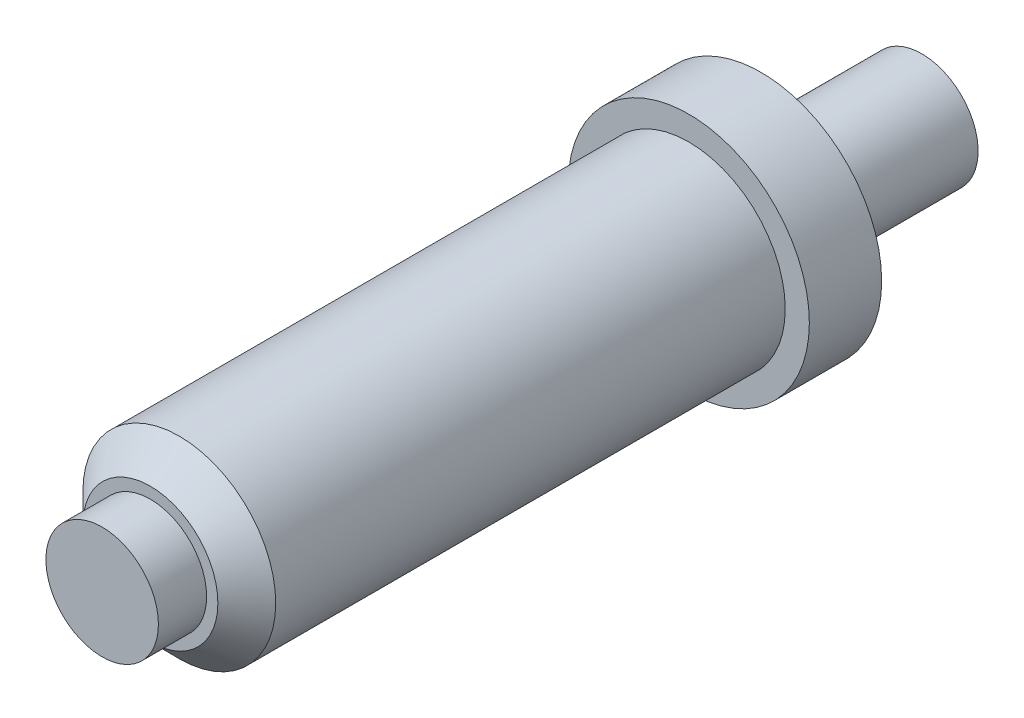
from build123d import *

# Parameters (mm, degrees)
SKETCH_1_R      = 6
EXTRUDE_1_DEPTH = 38
SKETCH_2_R      = 3.5
EXTRUDE_2_DEPTH = 3
SKETCH_4_R      = 3.5
EXTRUDE_3_DEPTH = 10
SKETCH_6_R      = 7.5
EXTRUDE_5_DEPTH = 4.5
CHAMFER_1_SIZE  = 1.8


with BuildPart() as part:
    # Эскиз1 → Бобышка-Вытянуть1 (new body)
    with BuildSketch(Plane.XY):
        Circle(SKETCH_1_R)
    extrude(amount=EXTRUDE_1_DEPTH)

    # Эскиз2 → Бобышка-Вытянуть2 (add)
    with BuildSketch(Plane.XY.offset(38)):
        Circle(SKETCH_2_R)
    extrude(amount=EXTRUDE_2_DEPTH)

    # Эскиз4 → Бобышка-Вытянуть3 (add)
    with BuildSketch(Plane(origin=(0, 0, 0), x_dir=(-1, 0, 0), z_dir=(0, 0, -1))):
        Circle(SKETCH_4_R)
    extrude(amount=EXTRUDE_3_DEPTH)

    # Эскиз6 → Бобышка-Вытянуть5 (add)
    with BuildSketch(Plane(origin=(0, 0, 0), x_dir=(-1, 0, 0), z_dir=(0, 0, -1))):
        Circle(SKETCH_6_R)
    extrude(amount=-EXTRUDE_5_DEPTH)

    # Фаска1
    chamfer_1_edges = [part.edges().sort_by_distance(p)[0] for p in [
        (-6, 0, 38),
    ]]
    chamfer(chamfer_1_edges, length=CHAMFER_1_SIZE)


solid = part.part
